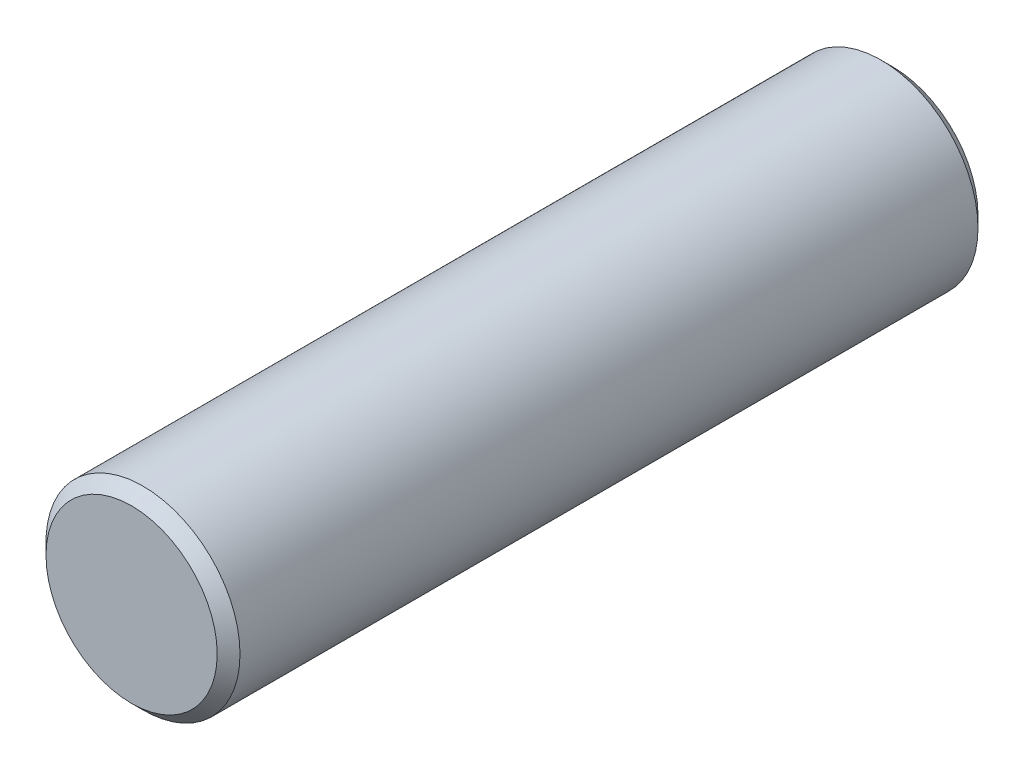
from build123d import *

# Parameters (mm, degrees)
SKETCH1_R           = 3.2385
BOSS_EXTRUDE1_DEPTH = 25.4
CHAMFER1_SIZE       = 0.381


with BuildPart() as part:
    # Sketch1 → Boss-Extrude1 (new body)
    with BuildSketch(Plane.XY):
        Circle(SKETCH1_R)
    extrude(amount=BOSS_EXTRUDE1_DEPTH)

    # Chamfer1
    chamfer1_edges = [part.edges().sort_by_distance(p)[0] for p in [
        (-3.2385, 0, 0),
        (-3.2385, 0, 25.4),
    ]]
    chamfer(chamfer1_edges, length=CHAMFER1_SIZE)


solid = part.part
